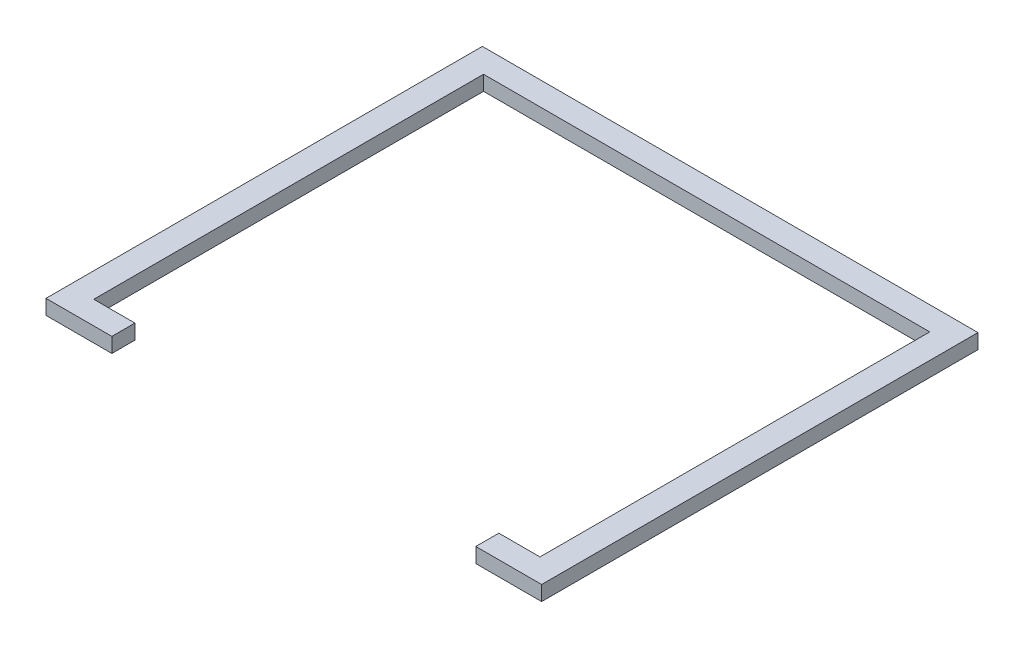
from build123d import *

# Parameters (mm, degrees)
EXTRUDE_1_DEPTH = 90


with BuildPart() as part:
    # 草图1 → 凸台-拉伸1 (new body)
    with BuildSketch(Plane(origin=(0, 0, 0), x_dir=(1, 0, 0), z_dir=(0, 1, 0))):
        Polygon((-1401.585973489, -1568.302458312), (-1801.585973489, -1568.302458312), (-1801.585973489, 1081.697541688), (1208.379600836, 1081.697541688), (1208.379600836, -1568.302458312), (808.379600836, -1568.302458312), (808.379600836, -1428.302458312), (1058.379600836, -1428.302458312), (1058.379600836, 938.784218378), (-1651.585973489, 938.784218378), (-1651.585973489, -1428.302458312), (-1401.585973489, -1428.302458312), align=None)
    extrude(amount=EXTRUDE_1_DEPTH)


solid = part.part
